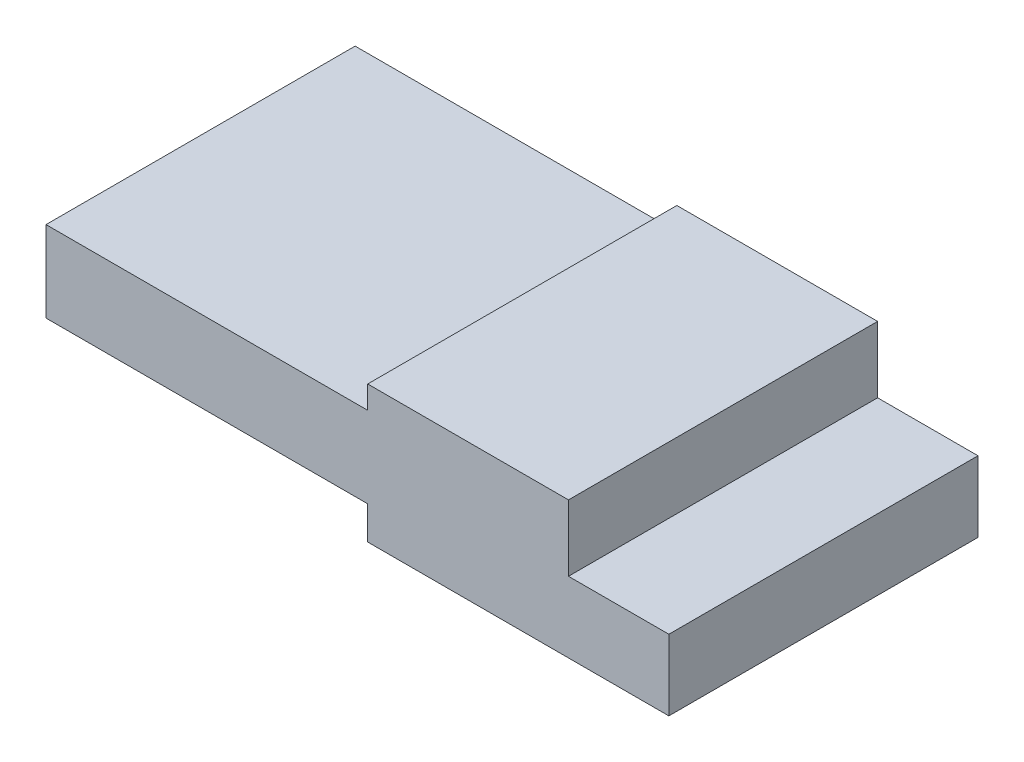
from build123d import *

# Parameters (mm, degrees)
BOSS_EXTRUDE1_DEPTH = 6.8834


with BuildPart() as part:
    # Sketch1 → Boss-Extrude1 (new body)
    with BuildSketch(Plane.XY):
        Polygon((0, 0), (0, 1.8034), (7.1628, 1.8034), (7.1628, 2.3114), (11.6332, 2.3114), (11.6332, 0.8382), (13.8684, 0.8382), (13.8684, -0.7366), (7.1628, -0.7366), (7.1628, 0), align=None)
    extrude(amount=BOSS_EXTRUDE1_DEPTH)


solid = part.part
